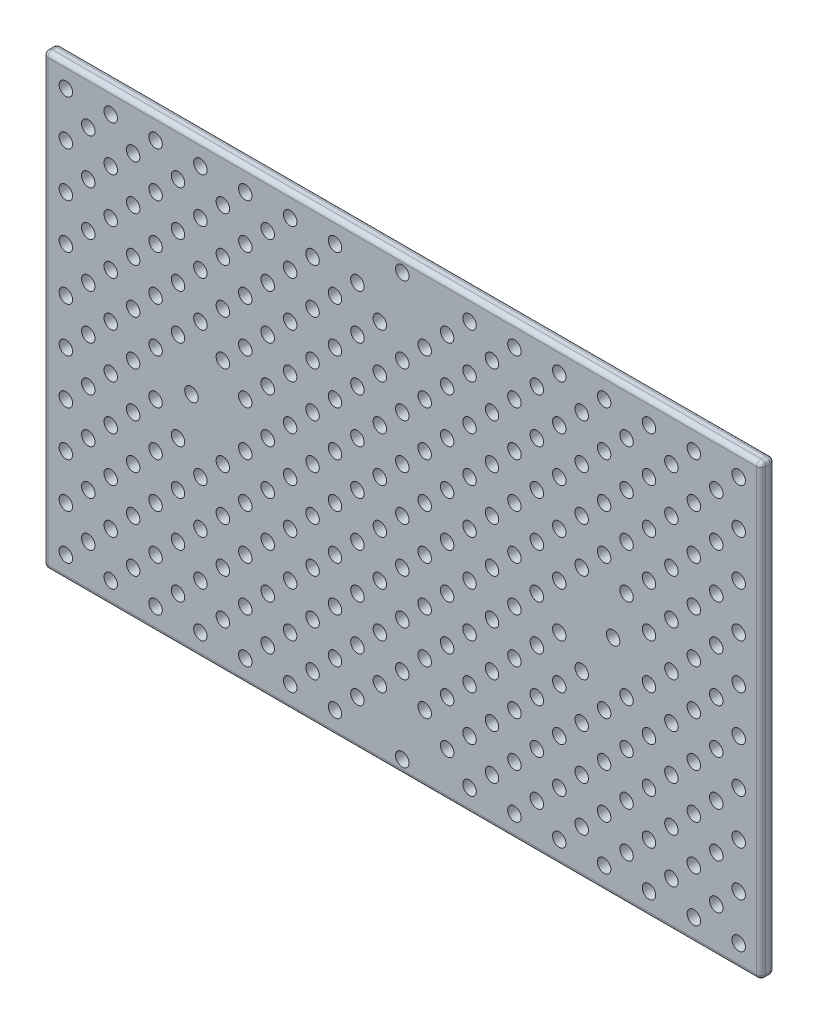
from build123d import *

# Parameters (mm, degrees)
ESQUISSE1_W             = 160
ESQUISSE1_H             = 100
BOSS_EXTRU_1_DEPTH      = 3
ESQUISSE2_R             = 1.5
ENL_V_MAT_EXTRU_1_DEPTH = 3
ESQUISSE3_R             = 1.5
ENL_V_MAT_EXTRU_2_DEPTH = 3
CONG_1_R                = 1


with BuildPart() as part:
    # Esquisse1 → Boss.-Extru.1 (new body)
    with BuildSketch(Plane.XY):
        with Locations((80, 50)):
            Rectangle(ESQUISSE1_W, ESQUISSE1_H)
    extrude(amount=BOSS_EXTRU_1_DEPTH)

    # Esquisse2 → Enlèv. mat.-Extru.1 (cut)
    with BuildSketch(Plane.XY.offset(3)):
        with Locations((80, 97)):
            Circle(ESQUISSE2_R)
        with Locations((127, 50)):
            Circle(ESQUISSE2_R)
        with Locations((80, 3)):
            Circle(ESQUISSE2_R)
        with Locations((33, 50)):
            Circle(ESQUISSE2_R)
    extrude(amount=-ENL_V_MAT_EXTRU_1_DEPTH, mode=Mode.SUBTRACT)

    # Esquisse3 → Enlèv. mat.-Extru.2 (cut)
    with BuildSketch(Plane.XY.offset(3)):
        with Locations((5, 95)):
            Circle(ESQUISSE3_R)
        with Locations((15, 95)):
            Circle(ESQUISSE3_R)
        with Locations((25, 95)):
            Circle(ESQUISSE3_R)
        with Locations((35, 95)):
            Circle(ESQUISSE3_R)
        with Locations((45, 95)):
            Circle(ESQUISSE3_R)
        with Locations((55, 95)):
            Circle(ESQUISSE3_R)
        with Locations((65, 95)):
            Circle(ESQUISSE3_R)
        with Locations((95, 95)):
            Circle(ESQUISSE3_R)
        with Locations((105, 95)):
            Circle(ESQUISSE3_R)
        with Locations((115, 95)):
            Circle(ESQUISSE3_R)
        with Locations((125, 95)):
            Circle(ESQUISSE3_R)
        with Locations((135, 95)):
            Circle(ESQUISSE3_R)
        with Locations((145, 95)):
            Circle(ESQUISSE3_R)
        with Locations((155, 95)):
            Circle(ESQUISSE3_R)
        with Locations((15, 85)):
            Circle(ESQUISSE3_R)
        with Locations((25, 85)):
            Circle(ESQUISSE3_R)
        with Locations((35, 85)):
            Circle(ESQUISSE3_R)
        with Locations((45, 85)):
            Circle(ESQUISSE3_R)
        with Locations((55, 85)):
            Circle(ESQUISSE3_R)
        with Locations((65, 85)):
            Circle(ESQUISSE3_R)
        with Locations((75, 85)):
            Circle(ESQUISSE3_R)
        with Locations((85, 85)):
            Circle(ESQUISSE3_R)
        with Locations((95, 85)):
            Circle(ESQUISSE3_R)
        with Locations((105, 85)):
            Circle(ESQUISSE3_R)
        with Locations((115, 85)):
            Circle(ESQUISSE3_R)
        with Locations((125, 85)):
            Circle(ESQUISSE3_R)
        with Locations((135, 85)):
            Circle(ESQUISSE3_R)
        with Locations((145, 85)):
            Circle(ESQUISSE3_R)
        with Locations((155, 85)):
            Circle(ESQUISSE3_R)
        with Locations((15, 75)):
            Circle(ESQUISSE3_R)
        with Locations((25, 75)):
            Circle(ESQUISSE3_R)
        with Locations((35, 75)):
            Circle(ESQUISSE3_R)
        with Locations((45, 75)):
            Circle(ESQUISSE3_R)
        with Locations((55, 75)):
            Circle(ESQUISSE3_R)
        with Locations((65, 75)):
            Circle(ESQUISSE3_R)
        with Locations((75, 75)):
            Circle(ESQUISSE3_R)
        with Locations((85, 75)):
            Circle(ESQUISSE3_R)
        with Locations((95, 75)):
            Circle(ESQUISSE3_R)
        with Locations((105, 75)):
            Circle(ESQUISSE3_R)
        with Locations((115, 75)):
            Circle(ESQUISSE3_R)
        with Locations((125, 75)):
            Circle(ESQUISSE3_R)
        with Locations((135, 75)):
            Circle(ESQUISSE3_R)
        with Locations((145, 75)):
            Circle(ESQUISSE3_R)
        with Locations((155, 75)):
            Circle(ESQUISSE3_R)
        with Locations((15, 65)):
            Circle(ESQUISSE3_R)
        with Locations((25, 65)):
            Circle(ESQUISSE3_R)
        with Locations((35, 65)):
            Circle(ESQUISSE3_R)
        with Locations((45, 65)):
            Circle(ESQUISSE3_R)
        with Locations((55, 65)):
            Circle(ESQUISSE3_R)
        with Locations((65, 65)):
            Circle(ESQUISSE3_R)
        with Locations((75, 65)):
            Circle(ESQUISSE3_R)
        with Locations((85, 65)):
            Circle(ESQUISSE3_R)
        with Locations((95, 65)):
            Circle(ESQUISSE3_R)
        with Locations((105, 65)):
            Circle(ESQUISSE3_R)
        with Locations((115, 65)):
            Circle(ESQUISSE3_R)
        with Locations((125, 65)):
            Circle(ESQUISSE3_R)
        with Locations((135, 65)):
            Circle(ESQUISSE3_R)
        with Locations((145, 65)):
            Circle(ESQUISSE3_R)
        with Locations((155, 65)):
            Circle(ESQUISSE3_R)
        with Locations((15, 55)):
            Circle(ESQUISSE3_R)
        with Locations((25, 55)):
            Circle(ESQUISSE3_R)
        with Locations((45, 55)):
            Circle(ESQUISSE3_R)
        with Locations((55, 55)):
            Circle(ESQUISSE3_R)
        with Locations((65, 55)):
            Circle(ESQUISSE3_R)
        with Locations((75, 55)):
            Circle(ESQUISSE3_R)
        with Locations((85, 55)):
            Circle(ESQUISSE3_R)
        with Locations((95, 55)):
            Circle(ESQUISSE3_R)
        with Locations((105, 55)):
            Circle(ESQUISSE3_R)
        with Locations((115, 55)):
            Circle(ESQUISSE3_R)
        with Locations((135, 55)):
            Circle(ESQUISSE3_R)
        with Locations((145, 55)):
            Circle(ESQUISSE3_R)
        with Locations((155, 55)):
            Circle(ESQUISSE3_R)
        with Locations((15, 45)):
            Circle(ESQUISSE3_R)
        with Locations((25, 45)):
            Circle(ESQUISSE3_R)
        with Locations((45, 45)):
            Circle(ESQUISSE3_R)
        with Locations((55, 45)):
            Circle(ESQUISSE3_R)
        with Locations((65, 45)):
            Circle(ESQUISSE3_R)
        with Locations((75, 45)):
            Circle(ESQUISSE3_R)
        with Locations((85, 45)):
            Circle(ESQUISSE3_R)
        with Locations((95, 45)):
            Circle(ESQUISSE3_R)
        with Locations((105, 45)):
            Circle(ESQUISSE3_R)
        with Locations((115, 45)):
            Circle(ESQUISSE3_R)
        with Locations((135, 45)):
            Circle(ESQUISSE3_R)
        with Locations((145, 45)):
            Circle(ESQUISSE3_R)
        with Locations((155, 45)):
            Circle(ESQUISSE3_R)
        with Locations((15, 35)):
            Circle(ESQUISSE3_R)
        with Locations((25, 35)):
            Circle(ESQUISSE3_R)
        with Locations((35, 35)):
            Circle(ESQUISSE3_R)
        with Locations((45, 35)):
            Circle(ESQUISSE3_R)
        with Locations((55, 35)):
            Circle(ESQUISSE3_R)
        with Locations((65, 35)):
            Circle(ESQUISSE3_R)
        with Locations((75, 35)):
            Circle(ESQUISSE3_R)
        with Locations((85, 35)):
            Circle(ESQUISSE3_R)
        with Locations((95, 35)):
            Circle(ESQUISSE3_R)
        with Locations((105, 35)):
            Circle(ESQUISSE3_R)
        with Locations((115, 35)):
            Circle(ESQUISSE3_R)
        with Locations((125, 35)):
            Circle(ESQUISSE3_R)
        with Locations((135, 35)):
            Circle(ESQUISSE3_R)
        with Locations((145, 35)):
            Circle(ESQUISSE3_R)
        with Locations((155, 35)):
            Circle(ESQUISSE3_R)
        with Locations((15, 25)):
            Circle(ESQUISSE3_R)
        with Locations((25, 25)):
            Circle(ESQUISSE3_R)
        with Locations((35, 25)):
            Circle(ESQUISSE3_R)
        with Locations((45, 25)):
            Circle(ESQUISSE3_R)
        with Locations((55, 25)):
            Circle(ESQUISSE3_R)
        with Locations((65, 25)):
            Circle(ESQUISSE3_R)
        with Locations((75, 25)):
            Circle(ESQUISSE3_R)
        with Locations((85, 25)):
            Circle(ESQUISSE3_R)
        with Locations((95, 25)):
            Circle(ESQUISSE3_R)
        with Locations((105, 25)):
            Circle(ESQUISSE3_R)
        with Locations((115, 25)):
            Circle(ESQUISSE3_R)
        with Locations((125, 25)):
            Circle(ESQUISSE3_R)
        with Locations((135, 25)):
            Circle(ESQUISSE3_R)
        with Locations((145, 25)):
            Circle(ESQUISSE3_R)
        with Locations((155, 25)):
            Circle(ESQUISSE3_R)
        with Locations((15, 15)):
            Circle(ESQUISSE3_R)
        with Locations((25, 15)):
            Circle(ESQUISSE3_R)
        with Locations((35, 15)):
            Circle(ESQUISSE3_R)
        with Locations((45, 15)):
            Circle(ESQUISSE3_R)
        with Locations((55, 15)):
            Circle(ESQUISSE3_R)
        with Locations((65, 15)):
            Circle(ESQUISSE3_R)
        with Locations((75, 15)):
            Circle(ESQUISSE3_R)
        with Locations((85, 15)):
            Circle(ESQUISSE3_R)
        with Locations((95, 15)):
            Circle(ESQUISSE3_R)
        with Locations((105, 15)):
            Circle(ESQUISSE3_R)
        with Locations((115, 15)):
            Circle(ESQUISSE3_R)
        with Locations((125, 15)):
            Circle(ESQUISSE3_R)
        with Locations((135, 15)):
            Circle(ESQUISSE3_R)
        with Locations((145, 15)):
            Circle(ESQUISSE3_R)
        with Locations((155, 15)):
            Circle(ESQUISSE3_R)
        with Locations((15, 5)):
            Circle(ESQUISSE3_R)
        with Locations((25, 5)):
            Circle(ESQUISSE3_R)
        with Locations((35, 5)):
            Circle(ESQUISSE3_R)
        with Locations((45, 5)):
            Circle(ESQUISSE3_R)
        with Locations((55, 5)):
            Circle(ESQUISSE3_R)
        with Locations((65, 5)):
            Circle(ESQUISSE3_R)
        with Locations((95, 5)):
            Circle(ESQUISSE3_R)
        with Locations((105, 5)):
            Circle(ESQUISSE3_R)
        with Locations((115, 5)):
            Circle(ESQUISSE3_R)
        with Locations((125, 5)):
            Circle(ESQUISSE3_R)
        with Locations((135, 5)):
            Circle(ESQUISSE3_R)
        with Locations((145, 5)):
            Circle(ESQUISSE3_R)
        with Locations((155, 5)):
            Circle(ESQUISSE3_R)
        with Locations((5, 85)):
            Circle(ESQUISSE3_R)
        with Locations((5, 75)):
            Circle(ESQUISSE3_R)
        with Locations((5, 65)):
            Circle(ESQUISSE3_R)
        with Locations((5, 55)):
            Circle(ESQUISSE3_R)
        with Locations((5, 45)):
            Circle(ESQUISSE3_R)
        with Locations((5, 35)):
            Circle(ESQUISSE3_R)
        with Locations((5, 25)):
            Circle(ESQUISSE3_R)
        with Locations((5, 15)):
            Circle(ESQUISSE3_R)
        with Locations((5, 5)):
            Circle(ESQUISSE3_R)
        with Locations((150, 90)):
            Circle(ESQUISSE3_R)
        with Locations((140, 90)):
            Circle(ESQUISSE3_R)
        with Locations((130, 90)):
            Circle(ESQUISSE3_R)
        with Locations((120, 90)):
            Circle(ESQUISSE3_R)
        with Locations((110, 90)):
            Circle(ESQUISSE3_R)
        with Locations((100, 90)):
            Circle(ESQUISSE3_R)
        with Locations((90, 90)):
            Circle(ESQUISSE3_R)
        with Locations((70, 90)):
            Circle(ESQUISSE3_R)
        with Locations((60, 90)):
            Circle(ESQUISSE3_R)
        with Locations((50, 90)):
            Circle(ESQUISSE3_R)
        with Locations((40, 90)):
            Circle(ESQUISSE3_R)
        with Locations((30, 90)):
            Circle(ESQUISSE3_R)
        with Locations((20, 90)):
            Circle(ESQUISSE3_R)
        with Locations((10, 90)):
            Circle(ESQUISSE3_R)
        with Locations((140, 80)):
            Circle(ESQUISSE3_R)
        with Locations((130, 80)):
            Circle(ESQUISSE3_R)
        with Locations((120, 80)):
            Circle(ESQUISSE3_R)
        with Locations((110, 80)):
            Circle(ESQUISSE3_R)
        with Locations((100, 80)):
            Circle(ESQUISSE3_R)
        with Locations((90, 80)):
            Circle(ESQUISSE3_R)
        with Locations((80, 80)):
            Circle(ESQUISSE3_R)
        with Locations((70, 80)):
            Circle(ESQUISSE3_R)
        with Locations((60, 80)):
            Circle(ESQUISSE3_R)
        with Locations((50, 80)):
            Circle(ESQUISSE3_R)
        with Locations((40, 80)):
            Circle(ESQUISSE3_R)
        with Locations((30, 80)):
            Circle(ESQUISSE3_R)
        with Locations((20, 80)):
            Circle(ESQUISSE3_R)
        with Locations((10, 80)):
            Circle(ESQUISSE3_R)
        with Locations((140, 70)):
            Circle(ESQUISSE3_R)
        with Locations((130, 70)):
            Circle(ESQUISSE3_R)
        with Locations((120, 70)):
            Circle(ESQUISSE3_R)
        with Locations((110, 70)):
            Circle(ESQUISSE3_R)
        with Locations((100, 70)):
            Circle(ESQUISSE3_R)
        with Locations((90, 70)):
            Circle(ESQUISSE3_R)
        with Locations((80, 70)):
            Circle(ESQUISSE3_R)
        with Locations((70, 70)):
            Circle(ESQUISSE3_R)
        with Locations((60, 70)):
            Circle(ESQUISSE3_R)
        with Locations((50, 70)):
            Circle(ESQUISSE3_R)
        with Locations((40, 70)):
            Circle(ESQUISSE3_R)
        with Locations((30, 70)):
            Circle(ESQUISSE3_R)
        with Locations((20, 70)):
            Circle(ESQUISSE3_R)
        with Locations((10, 70)):
            Circle(ESQUISSE3_R)
        with Locations((140, 60)):
            Circle(ESQUISSE3_R)
        with Locations((130, 60)):
            Circle(ESQUISSE3_R)
        with Locations((120, 60)):
            Circle(ESQUISSE3_R)
        with Locations((110, 60)):
            Circle(ESQUISSE3_R)
        with Locations((100, 60)):
            Circle(ESQUISSE3_R)
        with Locations((90, 60)):
            Circle(ESQUISSE3_R)
        with Locations((80, 60)):
            Circle(ESQUISSE3_R)
        with Locations((70, 60)):
            Circle(ESQUISSE3_R)
        with Locations((60, 60)):
            Circle(ESQUISSE3_R)
        with Locations((50, 60)):
            Circle(ESQUISSE3_R)
        with Locations((40, 60)):
            Circle(ESQUISSE3_R)
        with Locations((30, 60)):
            Circle(ESQUISSE3_R)
        with Locations((20, 60)):
            Circle(ESQUISSE3_R)
        with Locations((10, 60)):
            Circle(ESQUISSE3_R)
        with Locations((140, 50)):
            Circle(ESQUISSE3_R)
        with Locations((110, 50)):
            Circle(ESQUISSE3_R)
        with Locations((100, 50)):
            Circle(ESQUISSE3_R)
        with Locations((90, 50)):
            Circle(ESQUISSE3_R)
        with Locations((80, 50)):
            Circle(ESQUISSE3_R)
        with Locations((70, 50)):
            Circle(ESQUISSE3_R)
        with Locations((60, 50)):
            Circle(ESQUISSE3_R)
        with Locations((50, 50)):
            Circle(ESQUISSE3_R)
        with Locations((20, 50)):
            Circle(ESQUISSE3_R)
        with Locations((10, 50)):
            Circle(ESQUISSE3_R)
        with Locations((140, 40)):
            Circle(ESQUISSE3_R)
        with Locations((130, 40)):
            Circle(ESQUISSE3_R)
        with Locations((120, 40)):
            Circle(ESQUISSE3_R)
        with Locations((110, 40)):
            Circle(ESQUISSE3_R)
        with Locations((100, 40)):
            Circle(ESQUISSE3_R)
        with Locations((90, 40)):
            Circle(ESQUISSE3_R)
        with Locations((80, 40)):
            Circle(ESQUISSE3_R)
        with Locations((70, 40)):
            Circle(ESQUISSE3_R)
        with Locations((60, 40)):
            Circle(ESQUISSE3_R)
        with Locations((50, 40)):
            Circle(ESQUISSE3_R)
        with Locations((40, 40)):
            Circle(ESQUISSE3_R)
        with Locations((30, 40)):
            Circle(ESQUISSE3_R)
        with Locations((20, 40)):
            Circle(ESQUISSE3_R)
        with Locations((10, 40)):
            Circle(ESQUISSE3_R)
        with Locations((140, 30)):
            Circle(ESQUISSE3_R)
        with Locations((130, 30)):
            Circle(ESQUISSE3_R)
        with Locations((120, 30)):
            Circle(ESQUISSE3_R)
        with Locations((110, 30)):
            Circle(ESQUISSE3_R)
        with Locations((100, 30)):
            Circle(ESQUISSE3_R)
        with Locations((90, 30)):
            Circle(ESQUISSE3_R)
        with Locations((80, 30)):
            Circle(ESQUISSE3_R)
        with Locations((70, 30)):
            Circle(ESQUISSE3_R)
        with Locations((60, 30)):
            Circle(ESQUISSE3_R)
        with Locations((50, 30)):
            Circle(ESQUISSE3_R)
        with Locations((40, 30)):
            Circle(ESQUISSE3_R)
        with Locations((30, 30)):
            Circle(ESQUISSE3_R)
        with Locations((20, 30)):
            Circle(ESQUISSE3_R)
        with Locations((10, 30)):
            Circle(ESQUISSE3_R)
        with Locations((140, 20)):
            Circle(ESQUISSE3_R)
        with Locations((130, 20)):
            Circle(ESQUISSE3_R)
        with Locations((120, 20)):
            Circle(ESQUISSE3_R)
        with Locations((110, 20)):
            Circle(ESQUISSE3_R)
        with Locations((100, 20)):
            Circle(ESQUISSE3_R)
        with Locations((90, 20)):
            Circle(ESQUISSE3_R)
        with Locations((80, 20)):
            Circle(ESQUISSE3_R)
        with Locations((70, 20)):
            Circle(ESQUISSE3_R)
        with Locations((60, 20)):
            Circle(ESQUISSE3_R)
        with Locations((50, 20)):
            Circle(ESQUISSE3_R)
        with Locations((40, 20)):
            Circle(ESQUISSE3_R)
        with Locations((30, 20)):
            Circle(ESQUISSE3_R)
        with Locations((20, 20)):
            Circle(ESQUISSE3_R)
        with Locations((10, 20)):
            Circle(ESQUISSE3_R)
        with Locations((140, 10)):
            Circle(ESQUISSE3_R)
        with Locations((130, 10)):
            Circle(ESQUISSE3_R)
        with Locations((120, 10)):
            Circle(ESQUISSE3_R)
        with Locations((110, 10)):
            Circle(ESQUISSE3_R)
        with Locations((100, 10)):
            Circle(ESQUISSE3_R)
        with Locations((90, 10)):
            Circle(ESQUISSE3_R)
        with Locations((70, 10)):
            Circle(ESQUISSE3_R)
        with Locations((60, 10)):
            Circle(ESQUISSE3_R)
        with Locations((50, 10)):
            Circle(ESQUISSE3_R)
        with Locations((40, 10)):
            Circle(ESQUISSE3_R)
        with Locations((30, 10)):
            Circle(ESQUISSE3_R)
        with Locations((20, 10)):
            Circle(ESQUISSE3_R)
        with Locations((10, 10)):
            Circle(ESQUISSE3_R)
        with Locations((150, 80)):
            Circle(ESQUISSE3_R)
        with Locations((150, 70)):
            Circle(ESQUISSE3_R)
        with Locations((150, 60)):
            Circle(ESQUISSE3_R)
        with Locations((150, 50)):
            Circle(ESQUISSE3_R)
        with Locations((150, 40)):
            Circle(ESQUISSE3_R)
        with Locations((150, 30)):
            Circle(ESQUISSE3_R)
        with Locations((150, 20)):
            Circle(ESQUISSE3_R)
        with Locations((150, 10)):
            Circle(ESQUISSE3_R)
    extrude(amount=-ENL_V_MAT_EXTRU_2_DEPTH, mode=Mode.SUBTRACT)

    # Congé1
    cong_1_edges = [part.edges().sort_by_distance(p)[0] for p in [
        (160, 50, 3),
        (80, 100, 3),
        (0, 50, 3),
        (80, 100, 0),
        (160, 50, 0),
        (80, 0, 0),
        (0, 50, 0),
        (80, 0, 3),
        (0, 100, 1.5),
        (160, 100, 1.5),
        (160, 0, 1.5),
        (0, 0, 1.5),
    ]]
    fillet(cong_1_edges, radius=CONG_1_R)


solid = part.part
